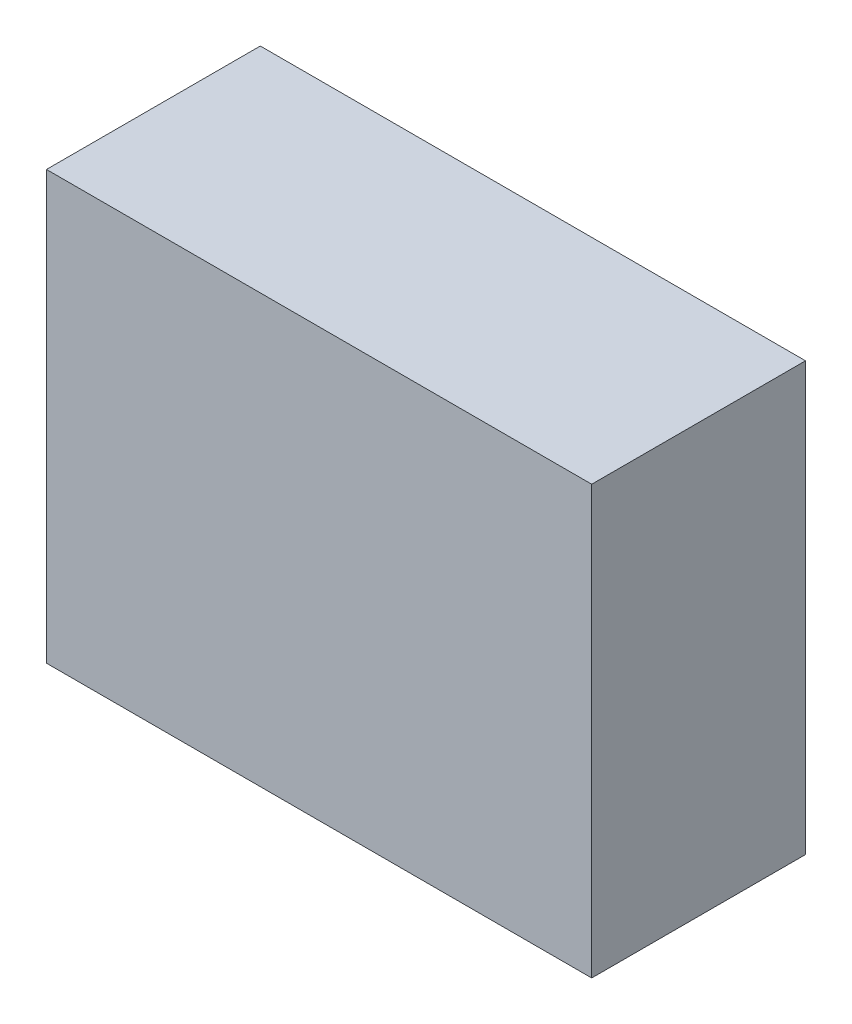
from build123d import *

# Parameters (mm, degrees)
ESQUISSE1_W        = 51
ESQUISSE1_H        = 40
BOSS_EXTRU_1_DEPTH = 20


with BuildPart() as part:
    # Esquisse1 → Boss.-Extru.1 (new body)
    with BuildSketch(Plane.XY):
        with Locations((25.5, 20)):
            Rectangle(ESQUISSE1_W, ESQUISSE1_H)
    extrude(amount=BOSS_EXTRU_1_DEPTH)


solid = part.part
